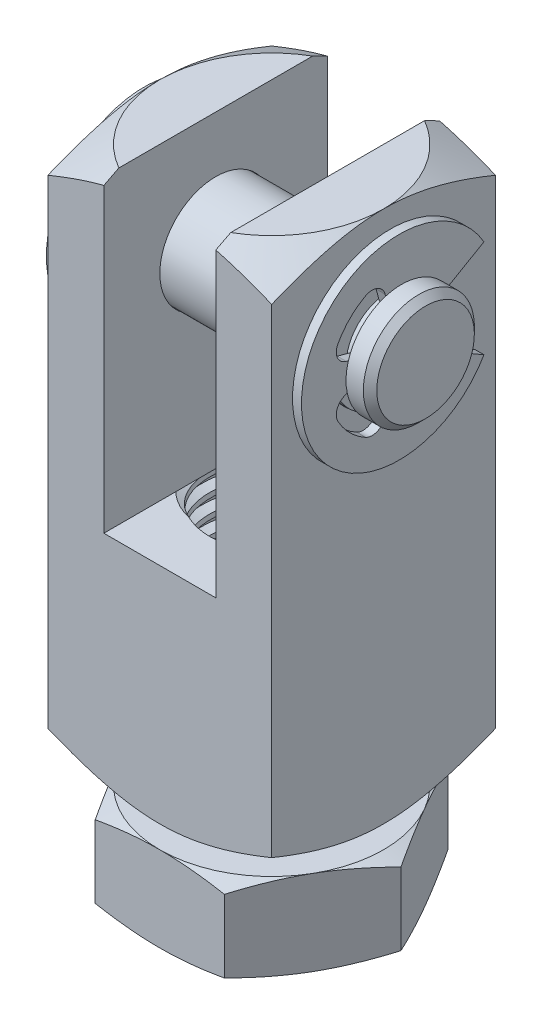
from build123d import *

# Parameters (mm, degrees)
SKETCH1_W               = 12.7
SKETCH1_H               = 30.226
EXTRUDE1_DEPTH          = 6.35
CUT_EXTRUDE1_DEPTH      = 32.531826398
CUT_EXTRUDE1_DEPTH_BACK = 32.531826398
SKETCH2_W               = 6.35
SKETCH2_H               = 17.526
SKETCH9_W               = 12.7
SKETCH9_H               = 3.175
SKETCH4_OUTSIDE_W       = 134.426
SKETCH4_OUTSIDE_H       = 134.426
SKETCH4_OUTSIDE_R       = 6.35
CUT_EXTRUDE3_DEPTH      = 32.531826398
CUT_EXTRUDE3_DRAFT      = -60
SKETCH5_OUTSIDE_W       = 134.426
SKETCH5_OUTSIDE_H       = 134.426
SKETCH5_OUTSIDE_R       = 6.35
CUT_EXTRUDE4_DEPTH      = 32.531826398
CUT_EXTRUDE4_DRAFT      = 60
SKETCH6_W               = 3.96875
SKETCH6_H               = 12.7
LPATTERN1_COUNT         = 2
LPATTERN1_PITCH         = 1.058333333
LPATTERN1_COL_COUNT     = 12
LPATTERN1_COL_PITCH     = 1.058333333
EXTRUDE2_DEPTH          = 4.826
SKETCH12_W              = 3.96875
SKETCH12_H              = 4.826
LPATTERN3_COUNT         = 2
LPATTERN3_PITCH         = 1.058333333
LPATTERN3_COL_COUNT     = 5
LPATTERN3_COL_PITCH     = 1.058333333
CHAMFER1_SIZE           = 0.381
EXTRUDE3_DEPTH          = 0.254


with BuildPart() as part:
    # Sketch1 → Extrude1 (new, symmetric)
    with BuildSketch(Plane.XY):
        with Locations((0, 15.113)):
            Rectangle(SKETCH1_W, SKETCH1_H)
    extrude(amount=EXTRUDE1_DEPTH, both=True)

    # Sketch2 → Cut-Extrude1 (cut, two sides: drawn at the far end of the back side and taken through both)
    with BuildSketch(Plane.XY.offset(-CUT_EXTRUDE1_DEPTH_BACK)):
        with Locations((0, 21.463)):
            Rectangle(SKETCH2_W, SKETCH2_H)
    extrude(amount=CUT_EXTRUDE1_DEPTH + CUT_EXTRUDE1_DEPTH_BACK, mode=Mode.SUBTRACT)

    # Sketch9 → Cut-Revolve3 (revolve, cut)
    with BuildSketch(Plane.XY, mode=Mode.PRIVATE) as cut_revolve3_sk:
        with Locations((0, 25.4635)):
            Rectangle(SKETCH9_W, SKETCH9_H)
    revolve(cut_revolve3_sk.sketch.rotate(Axis((-6.35, 23.876, 0), (-1, 0, 0)), 90), axis=Axis((-6.35, 23.876, 0), (-1, 0, 0)), mode=Mode.SUBTRACT)


with BuildPart() as cut_extrude3_tool:
    # Sketch4 outside → Cut-Extrude3 (with draft: the straight prism first)
    with BuildSketch(Plane(origin=(0, 30.226, 0), x_dir=(-1, 0, 0), z_dir=(0, 1, 0))):
        Rectangle(SKETCH4_OUTSIDE_W, SKETCH4_OUTSIDE_H)
        Circle(SKETCH4_OUTSIDE_R, mode=Mode.SUBTRACT)
    extrude(amount=-CUT_EXTRUDE3_DEPTH)
    # Cut-Extrude3: the draft: its side faces are tilted about the plane it starts from
    cut_extrude3_sides = [cut_extrude3_tool.faces().sort_by_distance(p)[0] for p in [
        (0, 13.960086801, -67.213),
        (-67.213, 13.960086801, 0),
        (0, 13.960086801, 67.213),
        (67.213, 13.960086801, 0),
        (6.35, 13.960086801, 0),
    ]]
    draft(cut_extrude3_sides, Plane(origin=(0, 30.226, 0), x_dir=(-1, 0, 0), z_dir=(0, 1, 0)), CUT_EXTRUDE3_DRAFT)


with BuildPart() as part_1:
    add(part.part)

    # Cut-Extrude3: cut by cut_extrude3_tool
    add(cut_extrude3_tool.part, mode=Mode.SUBTRACT)


with BuildPart() as cut_extrude4_tool:
    # Sketch5 outside → Cut-Extrude4 (with draft: the straight prism first)
    with BuildSketch(Plane(origin=(0, 0, 0), x_dir=(1, 0, 0), z_dir=(0, 1, 0))):
        Rectangle(SKETCH5_OUTSIDE_W, SKETCH5_OUTSIDE_H)
        Circle(SKETCH5_OUTSIDE_R, mode=Mode.SUBTRACT)
    extrude(amount=CUT_EXTRUDE4_DEPTH)
    # Cut-Extrude4: the draft: its side faces are tilted about the plane it starts from
    cut_extrude4_sides = [cut_extrude4_tool.faces().sort_by_distance(p)[0] for p in [
        (0, 16.265913199, 67.213),
        (67.213, 16.265913199, 0),
        (0, 16.265913199, -67.213),
        (-67.213, 16.265913199, 0),
        (-6.35, 16.265913199, 0),
    ]]
    draft(cut_extrude4_sides, Plane(origin=(0, 0, 0), x_dir=(1, 0, 0), z_dir=(0, 1, 0)), CUT_EXTRUDE4_DRAFT)


with BuildPart() as part_2:
    add(part_1.part)

    # Cut-Extrude4: cut by cut_extrude4_tool
    add(cut_extrude4_tool.part, mode=Mode.SUBTRACT)

    # Sketch8 → Cut-Revolve2 (revolve, cut)
    with BuildSketch(Plane.XY, mode=Mode.PRIVATE) as cut_revolve2_sk:
        Polygon((3.96875, 0), (0, 2.291358881), (0, 0), align=None)
    revolve(cut_revolve2_sk.sketch.rotate(Axis((0, 2.291358881, 0), (0, -1, 0)), 215.971128377), axis=Axis((0, 2.291358881, 0), (0, -1, 0)), mode=Mode.SUBTRACT)


with BuildPart() as body_2:
    # Sketch6 → Revolve1 (revolve)
    with BuildSketch(Plane.XY, mode=Mode.PRIVATE) as revolve1_sk:
        with Locations((1.984375, 6.35)):
            Rectangle(SKETCH6_W, SKETCH6_H)
    revolve(revolve1_sk.sketch.rotate(Axis((0, 0, 0), (0, -1, 0)), 180), axis=Axis((0, 0, 0), (0, -1, 0)))

    # Sketch7 → Cut-Revolve1 (revolve, cut)
    with BuildSketch(Plane.XY, mode=Mode.PRIVATE) as cut_revolve1_sk:
        Polygon((-3.986234159, 0.131131191), (-4.10862327, 1.049049528), (-3.49709816, 0.796930179), (-3.462129843, 0.534667797), align=None)
    cut_revolve1 = revolve(cut_revolve1_sk.sketch.rotate(Axis((0.150633003, 0, 0), (-0.13216372009101807, 0.9912279006826347, 0)), 180), axis=Axis((0.150633003, 0, 0), (-0.13216372009101807, 0.9912279006826347, 0)), mode=Mode.SUBTRACT)

    # LPattern1: Cut-Revolve1 ×2
    with Locations(*[(0, -i * LPATTERN1_PITCH, 0) for i in range(1, LPATTERN1_COUNT)]):
        add(cut_revolve1, mode=Mode.SUBTRACT)

    # LPattern1 col: Cut-Revolve1 ×12
    with Locations(*[(0, i * LPATTERN1_COL_PITCH, 0) for i in range(1, LPATTERN1_COL_COUNT)]):
        add(cut_revolve1, mode=Mode.SUBTRACT)


with BuildPart() as part_3:
    add(part_2.part)

    # Combine1: cut body 2
    add(body_2.part, mode=Mode.SUBTRACT)


with BuildPart() as body_2_2:
    # Sketch10 → Extrude2 (new body)
    with BuildSketch(Plane(origin=(0, -1.27, 0), x_dir=(-1, 0, 0), z_dir=(0, 1, 0))):
        Polygon((-7.332348419, 0), (-3.666174209, -6.35), (3.666174209, -6.35), (7.332348419, 0), (3.666174209, 6.35), (-3.666174209, 6.35), align=None)
    extrude(amount=-EXTRUDE2_DEPTH)

    # Sketch11 → Cut-Revolve4 (revolve, cut)
    with BuildSketch(Plane.XY, mode=Mode.PRIVATE) as cut_revolve4_sk:
        Polygon((6.35, -1.27), (7.332348419, -1.27), (7.332348419, -1.627545584), align=None)
        Polygon((6.35, -6.096), (7.332348419, -6.096), (7.332348419, -5.738454416), align=None)
    revolve(cut_revolve4_sk.sketch.rotate(Axis((0, -1.27, 0), (0, -1, 0)), 215.971128377), axis=Axis((0, -1.27, 0), (0, -1, 0)), mode=Mode.SUBTRACT)

    # Cut-Extrude5 cone 1 section (through the dimple's axis) → Cut-Extrude5 (revolve, cut)
    with BuildSketch(Plane(origin=(0, -1.27, 0), x_dir=(0, 0, 1), z_dir=(1, 0, 0))):
        Polygon((0, 0), (3.96875, 0), (0, 2.291358881), align=None)
    revolve(axis=Axis((0, -1.27, 0), (0, -1, 0)), mode=Mode.SUBTRACT)

    # Cut-Extrude6 cone 1 section (through the dimple's axis) → Cut-Extrude6 (revolve, cut)
    with BuildSketch(Plane(origin=(0, -6.096, 0), x_dir=(0, 0, -1), z_dir=(1, 0, 0))):
        Polygon((0, 0), (3.96875, 0), (0, 2.291358881), align=None)
    revolve(axis=Axis((0, -6.096, 0), (0, 1, 0)), mode=Mode.SUBTRACT)


with BuildPart() as body_3:
    # Sketch12 → Revolve2 (revolve)
    with BuildSketch(Plane.XY, mode=Mode.PRIVATE) as revolve2_sk:
        with Locations((1.984375, -3.683)):
            Rectangle(SKETCH12_W, SKETCH12_H)
    revolve(revolve2_sk.sketch.rotate(Axis((0, -1.27, 0), (0, -1, 0)), 215.971128377), axis=Axis((0, -1.27, 0), (0, -1, 0)))

    # Sketch13 → Cut-Revolve5 (revolve, cut)
    with BuildSketch(Plane.XY, mode=Mode.PRIVATE) as cut_revolve5_sk:
        Polygon((-3.986234159, -5.964868809), (-4.10862327, -5.046950472), (-3.49709816, -5.299069821), (-3.462129843, -5.561332203), align=None)
    cut_revolve5 = revolve(cut_revolve5_sk.sketch.rotate(Axis((0.150633003, -6.096, 0), (-0.13216372009101804, 0.9912279006826347, 0)), 180), axis=Axis((0.150633003, -6.096, 0), (-0.13216372009101804, 0.9912279006826347, 0)), mode=Mode.SUBTRACT)

    # LPattern3: Cut-Revolve5 ×2
    with Locations(*[(0, -i * LPATTERN3_PITCH, 0) for i in range(1, LPATTERN3_COUNT)]):
        add(cut_revolve5, mode=Mode.SUBTRACT)

    # LPattern3 col: Cut-Revolve5 ×5
    with Locations(*[(0, i * LPATTERN3_COL_PITCH, 0) for i in range(1, LPATTERN3_COL_COUNT)]):
        add(cut_revolve5, mode=Mode.SUBTRACT)


with BuildPart() as body_2_2_1:
    add(body_2_2.part)

    # Combine2: cut body 3
    add(body_3.part, mode=Mode.SUBTRACT)


with BuildPart() as body_3_2:
    # Sketch16 → Revolve3 (revolve)
    with BuildSketch(Plane.XY, mode=Mode.PRIVATE) as revolve3_sk:
        Polygon((-8.73125, 27.0256), (-7.366, 27.0256), (-7.366, 26.2636), (-6.604, 26.2636), (-6.604, 27.0256), (6.604, 27.0256), (6.604, 26.2636), (7.366, 26.2636), (7.366, 27.0256), (8.73125, 27.0256), (8.73125, 23.876), (-8.73125, 23.876), align=None)
    revolve(revolve3_sk.sketch.rotate(Axis((8.73125, 23.876, 0), (1, 0, 0)), 180), axis=Axis((8.73125, 23.876, 0), (1, 0, 0)))

    # Chamfer1
    chamfer1_edges = [body_3_2.edges().sort_by_distance(p)[0] for p in [
        (-8.73125, 27.0256, 0),
        (8.73125, 27.0256, 0),
    ]]
    chamfer(chamfer1_edges, length=CHAMFER1_SIZE)

    # Sketch17 → Extrude3 (add, symmetric)
    with BuildSketch(Plane(origin=(-6.985, 0, 0), x_dir=(0, 0, -1), z_dir=(1, 0, 0))):
        with BuildLine():
            Line((2.067722254, 25.0698), (4.806354388, 26.65095))
            ThreePointArc((4.806354388, 26.65095), (-5.5499, 23.876), (4.806354388, 21.10105))
            Line((4.806354388, 21.10105), (2.067722254, 22.6822))
            ThreePointArc((2.067722254, 22.6822), (0.913694963, 21.670145228), (-0.617956352, 21.569755497))
            Line((-0.617956352, 21.569755497), (-0.806195425, 20.867237713))
            ThreePointArc((-0.806195425, 20.867237713), (-1.242941812, 20.363693929), (-1.908701615, 20.396368596))
            ThreePointArc((-1.908701615, 20.396368596), (-2.806330038, 21.069669962), (-3.479631404, 21.967298385))
            ThreePointArc((-3.479631404, 21.967298385), (-3.512306071, 22.633058188), (-3.008762287, 23.069804575))
            Line((-3.008762287, 23.069804575), (-2.306244503, 23.258043648))
            ThreePointArc((-2.306244503, 23.258043648), (-2.3876, 23.876), (-2.306244503, 24.493956352))
            Line((-2.306244503, 24.493956352), (-3.008762287, 24.682195425))
            ThreePointArc((-3.008762287, 24.682195425), (-3.512306071, 25.118941812), (-3.479631404, 25.784701615))
            ThreePointArc((-3.479631404, 25.784701615), (-2.806330038, 26.682330038), (-1.908701615, 27.355631404))
            ThreePointArc((-1.908701615, 27.355631404), (-1.242941812, 27.388306071), (-0.806195425, 26.884762287))
            Line((-0.806195425, 26.884762287), (-0.617956352, 26.182244503))
            ThreePointArc((-0.617956352, 26.182244503), (0.913694963, 26.081854772), (2.067722254, 25.0698))
        make_face()
    extrude3 = extrude(amount=EXTRUDE3_DEPTH, both=True)

    # Mirror1: Extrude3 across plane
    add(extrude3.mirror(Plane(origin=(0, 0, 0), x_dir=(0, 0, 1), z_dir=(1, 0, 0))))


solid = Compound([part_3.part, body_2_2_1.part, body_3_2.part])
